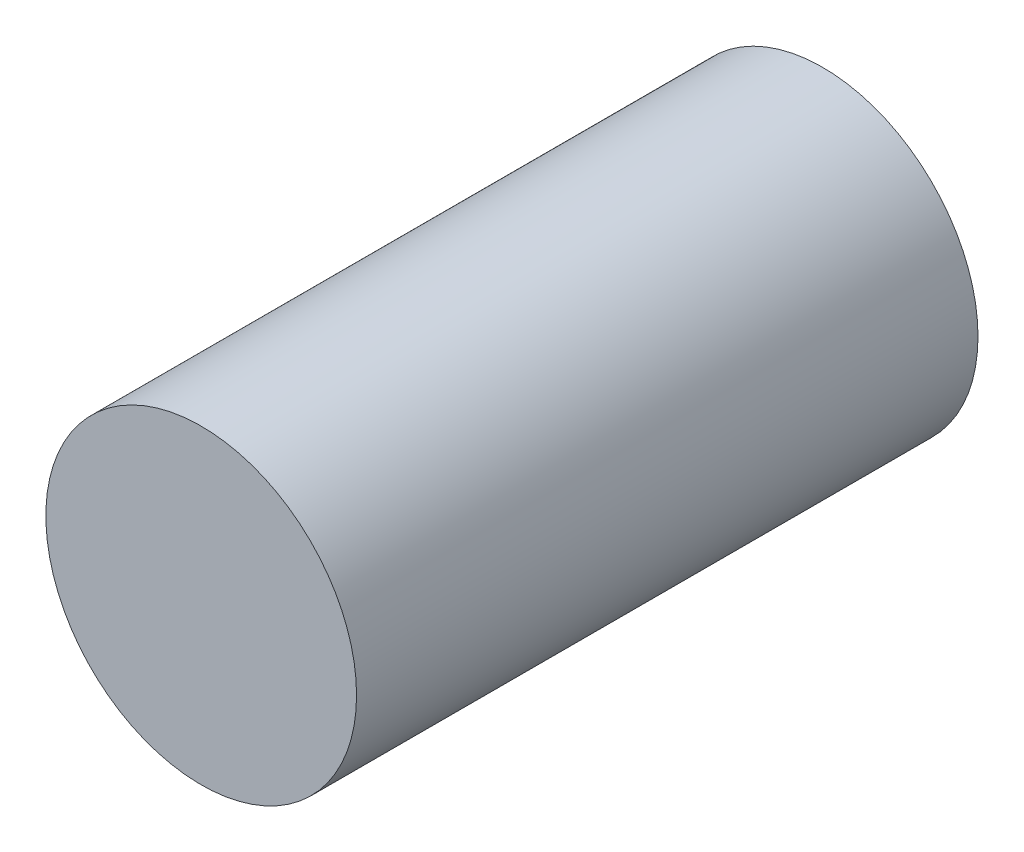
from build123d import *

# Parameters (mm, degrees)
SKETCH1_R      = 10
EXTRUDE1_DEPTH = 40


with BuildPart() as part:
    # Sketch1 → Extrude1 (new body)
    with BuildSketch(Plane.XY):
        Circle(SKETCH1_R)
    extrude(amount=EXTRUDE1_DEPTH)


solid = part.part
